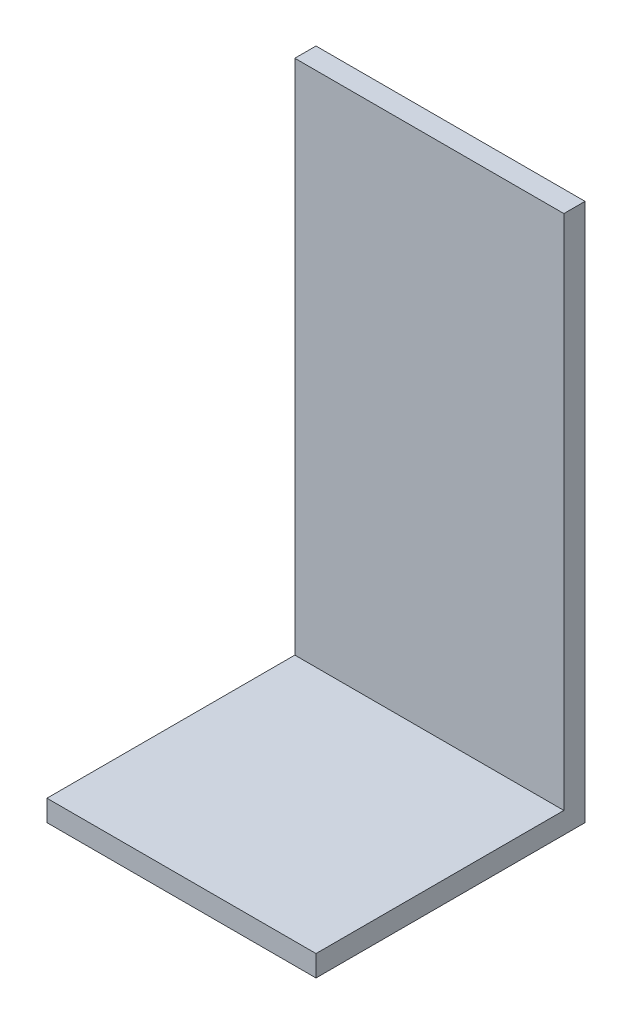
from build123d import *

# Parameters (mm, degrees)
SKETCH1_W           = 25.4
SKETCH1_H           = 25.4
BOSS_EXTRUDE1_DEPTH = 2
SKETCH2_W           = 25.4
SKETCH2_H           = 2
BOSS_EXTRUDE2_DEPTH = 48.8


with BuildPart() as part:
    # Sketch1 → Boss-Extrude1 (new body)
    with BuildSketch(Plane(origin=(0, 0, 0), x_dir=(1, 0, 0), z_dir=(0, 1, 0))):
        with Locations((-0.420409016, -1.575482221)):
            Rectangle(SKETCH1_W, SKETCH1_H)
    extrude(amount=BOSS_EXTRUDE1_DEPTH)

    # Sketch2 → Boss-Extrude2 (add)
    with BuildSketch(Plane(origin=(0, 2, 0), x_dir=(1, 0, 0), z_dir=(0, 1, 0))):
        with Locations((-0.420409016, 10.124517779)):
            Rectangle(SKETCH2_W, SKETCH2_H)
    extrude(amount=BOSS_EXTRUDE2_DEPTH)


solid = part.part
